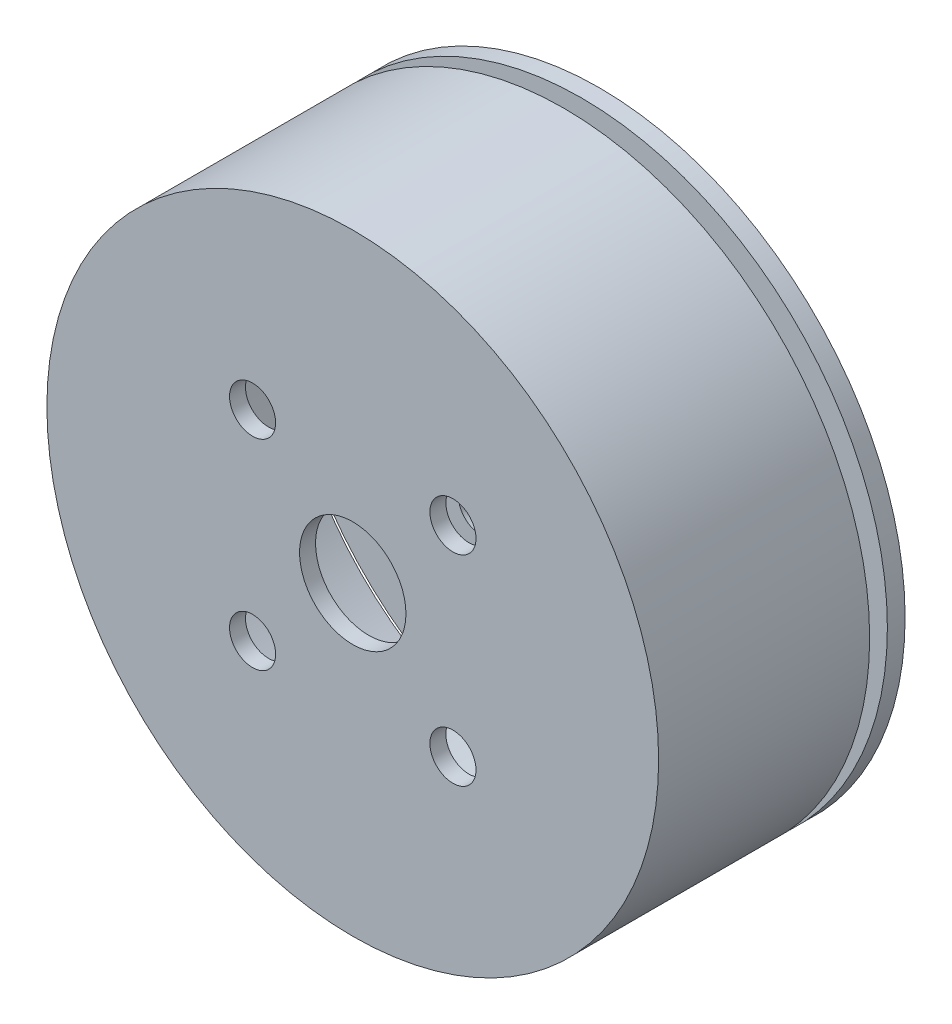
from build123d import *

# Parameters (mm, degrees)
SKETCH_1_R          = 17.25
EXTRUDE_1_DEPTH     = 13.9
SKETCH_3_R          = 17.25
CUT_EXTRUDE_2_DEPTH = 1
SKETCH_4_R          = 16
CUT_EXTRUDE_4_DEPTH = 11
SKETCH_5_R          = 1.3
SKETCH_5_R_2        = 3
CUT_EXTRUDE_5_DEPTH = 7.5
SKETCH_6_R          = 1.3
SKETCH_6_R_2        = 3
CUT_EXTRUDE_6_DEPTH = 10


with BuildPart() as part:
    # 草图1 → 凸台-拉伸1 (new body)
    with BuildSketch(Plane.XY):
        Circle(SKETCH_1_R)
    extrude(amount=EXTRUDE_1_DEPTH)

    # 草图3 → 切除-拉伸2 (cut)
    with BuildSketch(Plane(origin=(0, 0, 1), x_dir=(-1, 0, 0), z_dir=(0, 0, -1))):
        Circle(SKETCH_3_R)
    extrude(amount=-CUT_EXTRUDE_2_DEPTH, mode=Mode.SUBTRACT)

    # 草图4 → 切除-拉伸4 (cut)
    with BuildSketch(Plane(origin=(0, 0, 2), x_dir=(-1, 0, 0), z_dir=(0, 0, -1))):
        Circle(SKETCH_4_R)
    extrude(amount=-CUT_EXTRUDE_4_DEPTH, mode=Mode.SUBTRACT)

    # 草图5 → 切除-拉伸5 (cut, symmetric)
    with BuildSketch(Plane.XY.offset(13.9)):
        with Locations((5.65, 5.65)):
            Circle(SKETCH_5_R)
        with Locations((5.65, -5.65)):
            Circle(SKETCH_5_R)
        with Locations((-5.65, -5.65)):
            Circle(SKETCH_5_R)
        with Locations((-5.65, 5.65)):
            Circle(SKETCH_5_R)
        Circle(SKETCH_5_R_2)
    extrude(amount=CUT_EXTRUDE_5_DEPTH, both=True, mode=Mode.SUBTRACT)

    # 草图6 → 切除-拉伸6 (cut)
    with BuildSketch(Plane(origin=(0, 0, 0), x_dir=(-1, 0, 0), z_dir=(0, 0, -1))):
        with Locations((-5.65, 5.65)):
            Circle(SKETCH_6_R)
        with Locations((5.65, 5.65)):
            Circle(SKETCH_6_R)
        with Locations((5.65, -5.65)):
            Circle(SKETCH_6_R)
        with Locations((-5.65, -5.65)):
            Circle(SKETCH_6_R)
        Circle(SKETCH_6_R_2)
    extrude(amount=-CUT_EXTRUDE_6_DEPTH, mode=Mode.SUBTRACT)


solid = part.part
